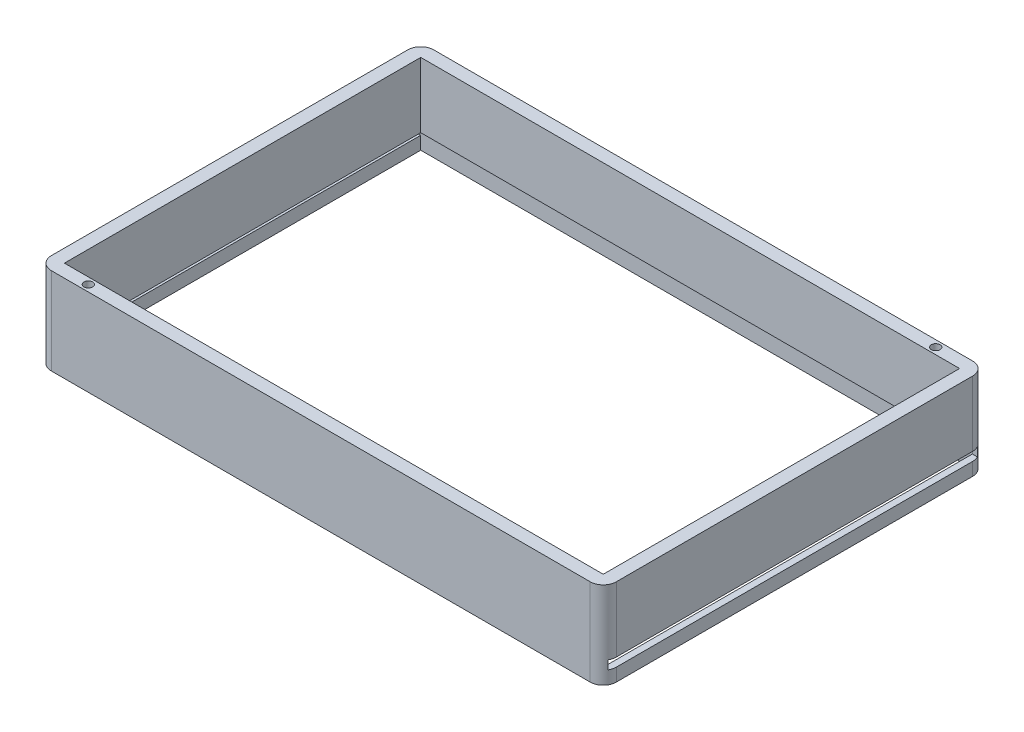
from build123d import *

# Parameters (mm, degrees)
SKETCH_1_R          = 1
SKETCH_1_W          = 124
SKETCH_1_H          = 82
EXTRUDE_2_DEPTH     = 20
SKETCH_2_W          = 127
SKETCH_2_H          = 85
CUT_EXTRUDE_1_DEPTH = 5
SKETCH_3_W          = 84.949028024
SKETCH_3_H          = 2
CUT_EXTRUDE_3_DEPTH = 164


with BuildPart() as part:
    # Эскиз1 → Бобышка-Вытянуть2 (new body)
    with BuildSketch(Plane(origin=(0, 0, 0), x_dir=(1, 0, 0), z_dir=(0, 1, 0))):
        with BuildLine():
            Line((3, 0), (127, 0))
            ThreePointArc((127, 0), (129.121320344, 0.878679656), (130, 3))
            Line((130, 3), (130, 85))
            ThreePointArc((130, 85), (129.121320344, 87.121320344), (127, 88))
            Line((127, 88), (3, 88))
            ThreePointArc((3, 88), (0.878679656, 87.121320344), (0, 85))
            Line((0, 85), (0, 3))
            ThreePointArc((0, 3), (0.878679656, 0.878679656), (3, 0))
        make_face()
        with Locations((120, 86.5)):
            Circle(SKETCH_1_R, mode=Mode.SUBTRACT)
        with Locations((10, 1.5)):
            Circle(SKETCH_1_R, mode=Mode.SUBTRACT)
        with Locations((65, 44)):
            Rectangle(SKETCH_1_W, SKETCH_1_H, mode=Mode.SUBTRACT)
    extrude(amount=EXTRUDE_2_DEPTH)

    # Эскиз2 → Вырез-Вытянуть1 (cut)
    with BuildSketch(Plane(origin=(0, 0, 0), x_dir=(-1, 0, 0), z_dir=(0, -1, 0))):
        with Locations((-65, 44)):
            Rectangle(SKETCH_2_W, SKETCH_2_H)
    extrude(amount=-CUT_EXTRUDE_1_DEPTH, mode=Mode.SUBTRACT)

    # Эскиз3 → Вырез-Вытянуть3 (cut)
    with BuildSketch(Plane.ZY):
        with Locations((-43.966717109, 3.987675958)):
            Rectangle(SKETCH_3_W, SKETCH_3_H)
    extrude(amount=-CUT_EXTRUDE_3_DEPTH, mode=Mode.SUBTRACT)


solid = part.part
